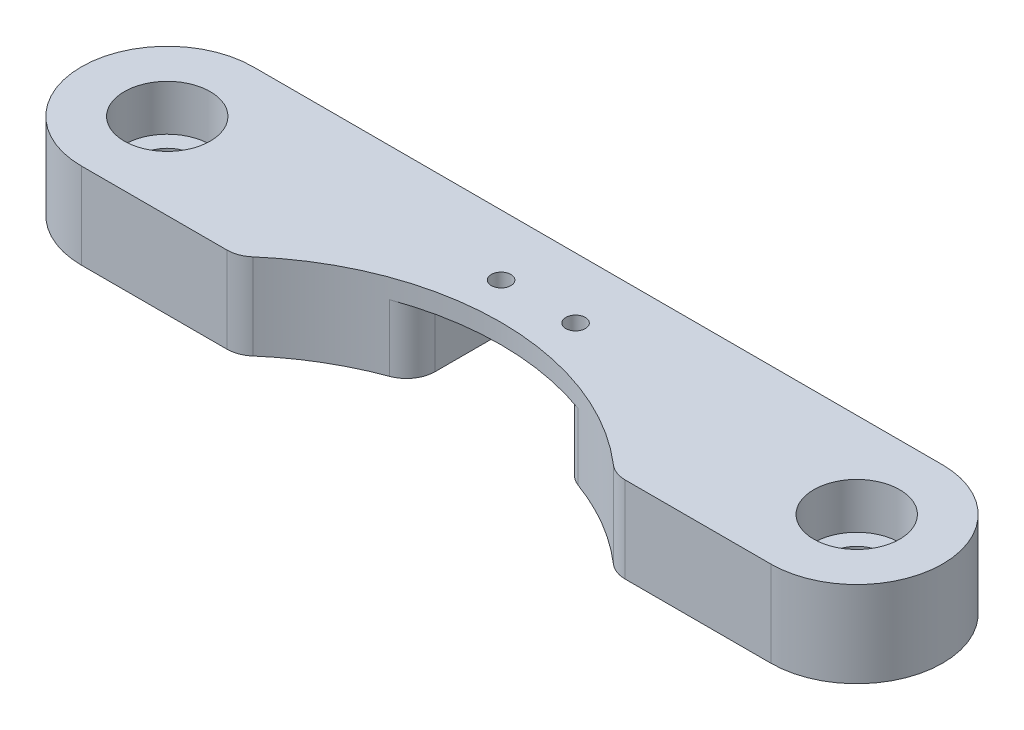
from build123d import *

# Parameters (mm, degrees)
SKETCH1_R           = 2.25
BOSS_EXTRUDE1_DEPTH = 7.5
SKETCH2_R           = 0.85
CUT_EXTRUDE1_DEPTH  = 8.5
SKETCH3_R           = 0.85
BOSS_EXTRUDE2_DEPTH = 1.7
SKETCH4_W           = 13.2
SKETCH4_H           = 9.425338572
CUT_EXTRUDE2_DEPTH  = 5.8
FILLET1_R           = 2.5
SKETCH5_R           = 3.75
CUT_EXTRUDE3_DEPTH  = 4


with BuildPart() as part:
    # Sketch1 → Boss-Extrude1 (new body)
    with BuildSketch(Plane(origin=(0, 45, 0), x_dir=(1, 0, 0), z_dir=(0, 1, 0))):
        with BuildLine():
            Line((-16.524067706, 17.5), (-30.2, 17.5))
            ThreePointArc((-30.2, 17.5), (-37.7, 25), (-30.2, 32.5))
            Line((-30.2, 32.5), (30, 32.5))
            ThreePointArc((30, 32.5), (37.5, 25), (30, 17.5))
            Line((30, 17.5), (16.324067706, 17.5))
            ThreePointArc((16.324067706, 17.5), (-0.1, 24), (-16.524067706, 17.5))
        make_face()
        with Locations((-30.2, 25)):
            Circle(SKETCH1_R, mode=Mode.SUBTRACT)
        with Locations((30, 25)):
            Circle(SKETCH1_R, mode=Mode.SUBTRACT)
    extrude(amount=BOSS_EXTRUDE1_DEPTH)

    # Sketch2 → Cut-Extrude1 (cut, through all)
    with BuildSketch(Plane.XZ.offset(-45)):
        with Locations((-3.25, -27.2)):
            Circle(SKETCH2_R)
        with Locations((3.25, -27.2)):
            Circle(SKETCH2_R)
    extrude(amount=-CUT_EXTRUDE1_DEPTH, mode=Mode.SUBTRACT)

    # Sketch3 → Boss-Extrude2 (add)
    with BuildSketch(Plane.XZ.offset(-52.5)):
        with BuildLine():
            Line((-3.25, -24.7), (3.25, -24.7))
            ThreePointArc((3.25, -24.7), (5.75, -27.2), (3.25, -29.7))
            Line((3.25, -29.7), (-3.25, -29.7))
            ThreePointArc((-3.25, -29.7), (-5.75, -27.2), (-3.25, -24.7))
        make_face()
        with Locations((3.25, -27.2)):
            Circle(SKETCH3_R, mode=Mode.SUBTRACT)
        with Locations((-3.25, -27.2)):
            Circle(SKETCH3_R, mode=Mode.SUBTRACT)
    extrude(amount=BOSS_EXTRUDE2_DEPTH)

    # Sketch4 → Cut-Extrude2 (cut)
    with BuildSketch(Plane(origin=(0, 45, 0), x_dir=(1, 0, 0), z_dir=(0, 1, 0))):
        with Locations((-0.1, 27.787330714)):
            Rectangle(SKETCH4_W, SKETCH4_H)
    extrude(amount=CUT_EXTRUDE2_DEPTH, mode=Mode.SUBTRACT)

    # Fillet1
    fillet1_edges = [part.edges().sort_by_distance(p)[0] for p in [
        (-16.524067706, 48.75, -17.5),
        (16.324067706, 48.75, -17.5),
        (-6.7, 47.9, -32.5),
        (-6.7, 47.9, -23.074661428),
        (6.5, 47.9, -23.074661428),
        (6.5, 47.9, -32.5),
    ]]
    fillet(fillet1_edges, radius=FILLET1_R)

    # Sketch5 → Cut-Extrude3 (cut)
    with BuildSketch(Plane(origin=(0, 52.5, 0), x_dir=(1, 0, 0), z_dir=(0, 1, 0))):
        with Locations((-30.2, 25)):
            Circle(SKETCH5_R)
        with Locations((30, 25)):
            Circle(SKETCH5_R)
    extrude(amount=-CUT_EXTRUDE3_DEPTH, mode=Mode.SUBTRACT)


solid = part.part
